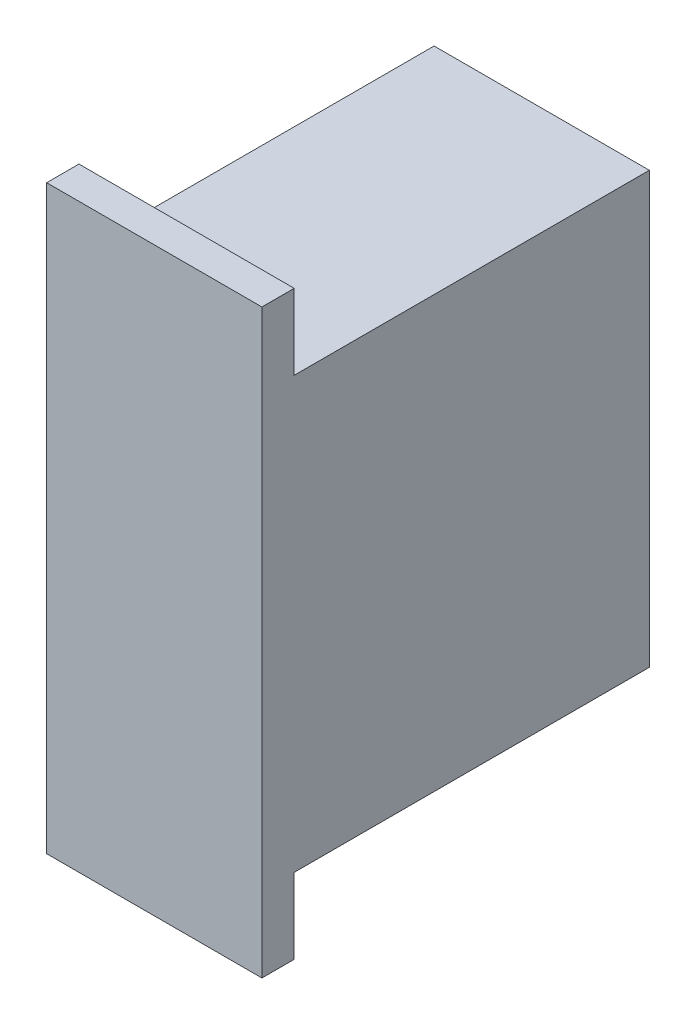
from build123d import *

# Parameters (mm, degrees)
SKETCH1_W           = 20
SKETCH1_H           = 40
BOSS_EXTRUDE1_DEPTH = 36
SKETCH2_W           = 20
SKETCH2_H           = 7
BOSS_EXTRUDE5_DEPTH = 3


with BuildPart() as part:
    # Sketch1 → Boss-Extrude1 (new body)
    with BuildSketch(Plane.XY):
        Rectangle(SKETCH1_W, SKETCH1_H)
    extrude(amount=BOSS_EXTRUDE1_DEPTH)

    # Sketch2 → Boss-Extrude5 (add)
    with BuildSketch(Plane.XY.offset(36)):
        with Locations((0, 23.5)):
            Rectangle(SKETCH2_W, SKETCH2_H)
        with Locations((0, -23.5)):
            Rectangle(SKETCH2_W, SKETCH2_H)
    extrude(amount=-BOSS_EXTRUDE5_DEPTH)


solid = part.part
